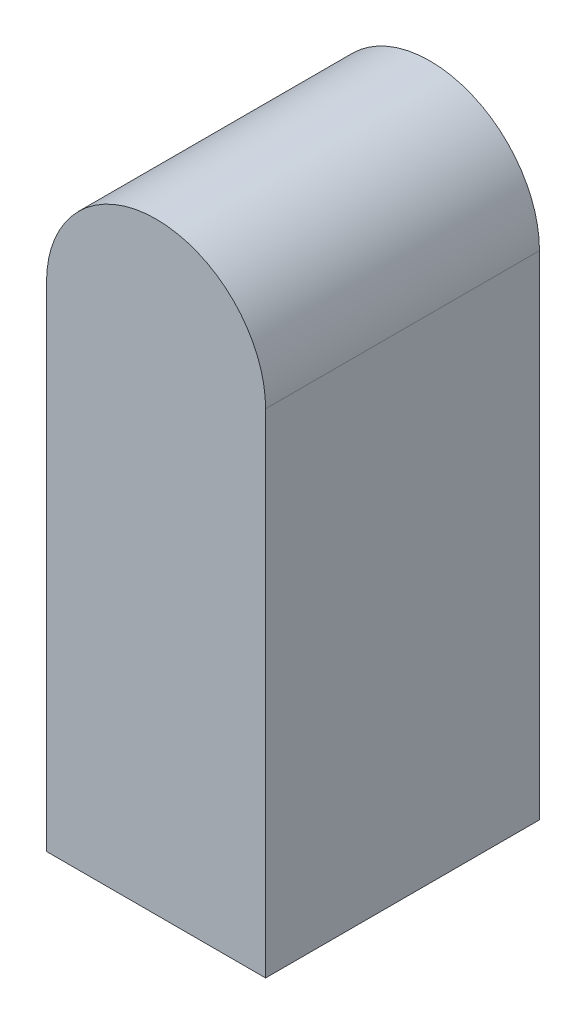
from build123d import *

# Parameters (mm, degrees)
ESTRUSIONE_ESTRUSIONE1_DEPTH = 100


with BuildPart() as part:
    # Schizzo1 → Estrusione-Estrusione1 (new body)
    with BuildSketch(Plane.XY):
        with BuildLine():
            Line((-40, 0), (-40, -180))
            Line((-40, -180), (40, -180))
            Line((40, -180), (40, 0))
            ThreePointArc((40, 0), (0, 40), (-40, 0))
        make_face()
    extrude(amount=ESTRUSIONE_ESTRUSIONE1_DEPTH)


solid = part.part
